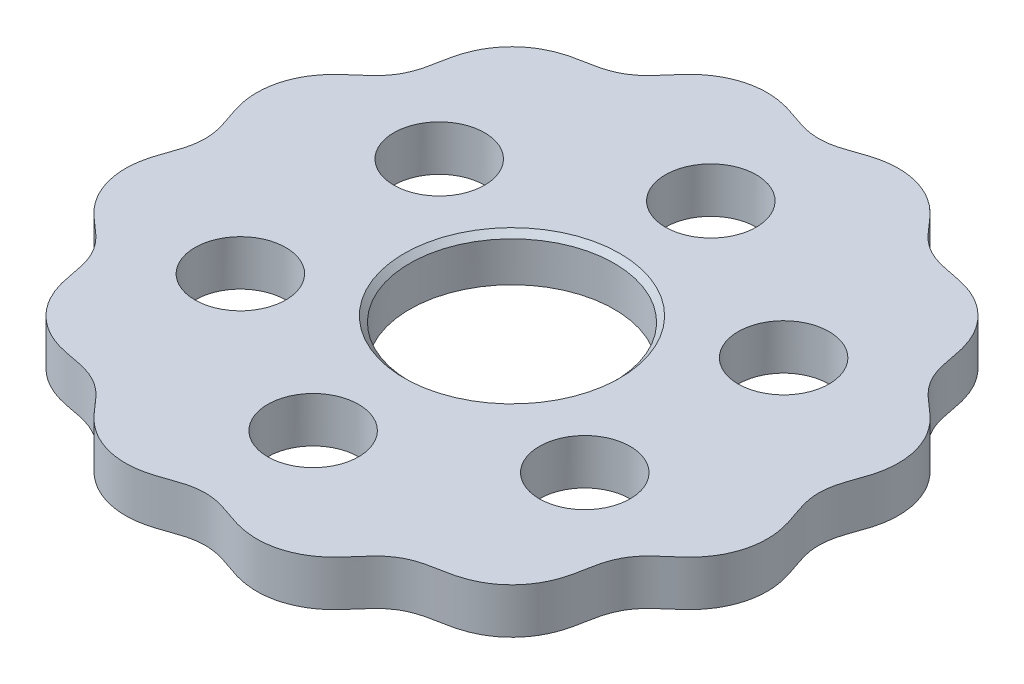
from build123d import *

# Parameters (mm, degrees)
BOSS_EXTRUDE1_DEPTH = 4
SKETCH2_R           = 9
CUT_EXTRUDE1_DEPTH  = 4
SKETCH3_R           = 4
CUT_EXTRUDE2_DEPTH  = 10
CHAMFER1_SIZE       = 0.5


with BuildPart() as part:
    # Sketch1 → Boss-Extrude1 (new body)
    with BuildSketch(Plane(origin=(0, 0, 0), x_dir=(1, 0, 0), z_dir=(0, 1, 0))):
        with BuildLine():
            add(Edge.make_bspline(
                [(27, 0), (27, -0.029843366), (27.000471765, -0.074622861), (27.002044312, -0.148526868), (27.00628274, -0.263641883), (27.012393312, -0.37537519), (27.022230728, -0.497376741), (27.03712787, -0.637409177), (27.055598892, -0.778657943), (27.077542429, -0.919236466), (27.10915909, -1.093914746), (27.153510714, -1.302382782), (27.213872001, -1.543652209), (27.292990208, -1.816594021), (27.380165946, -2.087067057), (27.473046955, -2.355596024), (27.59295323, -2.689915261), (27.737681672, -3.090771227), (27.896172741, -3.562218272), (28.063427098, -4.16720549), (28.192540962, -4.842140507), (28.27465216, -5.786972017), (28.188464813, -6.990666987), (27.810987259, -8.347530847), (27.084626542, -9.647288981), (26.186127024, -10.671759321), (25.238199473, -11.471905983), (24.372586568, -12.191039395), (23.620853175, -13.038066251), (23.063039846, -14.02515248), (22.723156568, -15.104958367), (22.540550691, -16.214937479), (22.311404563, -17.43453731), (21.855929835, -18.718964056), (21.078704809, -19.98167216), (19.944308098, -21.108107003), (18.676174537, -21.876448471), (17.388781942, -22.323268693), (16.168451287, -22.547256528), (15.058830974, -22.733329752), (13.981568641, -23.081976643), (12.999619336, -23.648776549), (12.158914933, -24.407246222), (11.442896635, -25.275122476), (10.638838498, -26.220033221), (9.608314539, -27.111685537), (8.308952362, -27.825947245), (6.766296625, -28.245380094), (5.284152953, -28.287347119), (3.944032474, -28.039779895), (2.773211959, -27.628533705), (1.720668629, -27.231619492), (0.615634296, -26.985876537), (-0.518110613, -26.975188118), (-1.627571272, -27.202504562), (-2.683196056, -27.592492668), (-3.85007581, -28.013459209), (-5.186489321, -28.279516523), (-6.675320744, -28.258945705), (-8.23569736, -27.856929805), (-9.556659448, -27.149289793), (-10.607747583, -26.253130508), (-11.424252904, -25.299053941), (-12.145498663, -24.42069207), (-12.993060357, -23.652288656), (-13.985080986, -23.079285719), (-15.074206005, -22.729094793), (-16.19549609, -22.543507448), (-17.430034502, -22.313659592), (-18.731806288, -21.851849103), (-20.00536007, -21.06206781), (-21.134053807, -19.912092302), (-21.896670407, -18.633242382), (-22.334837666, -17.34296826), (-22.553915449, -16.121964922), (-22.743815495, -15.012754256), (-23.101301577, -13.938157258), (-23.677046205, -12.961423213), (-24.442102548, -12.127035027), (-25.312028672, -11.413847459), (-26.253730695, -10.605690826), (-27.138488985, -9.569154166), (-27.843610955, -8.264810031), (-28.252168407, -6.719238227), (-28.283728903, -5.236836375), (-28.027183298, -3.898472997), (-27.611098664, -2.729600507), (-27.217360546, -1.675636661), (-26.980474187, -0.568422897), (-26.980139595, 0.565370052), (-27.216449027, 1.67272244), (-27.60997034, 2.726782849), (-28.02635931, 3.895531876), (-28.283483847, 5.233779265), (-28.252595633, 6.716195557), (-27.844741826, 8.261952815), (-27.140211848, 9.56661709), (-26.255901422, 10.60354088), (-25.314412694, 11.411968505), (-24.444361726, 12.124983159), (-23.678884788, 12.958963568), (-23.102563793, 13.935358019), (-22.744504016, 15.00977844), (-22.554344619, 16.118960967), (-22.335575088, 17.340005427), (-21.897967172, 18.63046337), (-21.135929645, 19.909659005), (-20.007760124, 21.060147962), (-18.734564151, 21.850507376), (-17.432988943, 22.312886202), (-16.19849739, 22.543076542), (-15.077182613, 22.728437444), (-13.987888625, 23.078054409), (-12.995530871, 23.650473301), (-12.147556588, 24.418443199), (-11.426126663, 25.29667015), (-10.609894266, 26.250958295), (-9.559200101, 27.147571895), (-8.238559851, 27.855810786), (-6.678365913, 28.258537364), (-5.189544443, 28.279782546), (-3.853010553, 28.014301607), (-2.686012173, 27.593622942), (-1.63049252, 27.203396622), (-0.521165891, 26.975495221), (0.612584807, 26.985514684), (1.717761904, 27.230689313), (2.77039276, 27.62740848), (3.941085326, 28.038974558), (5.281094376, 28.287123159), (6.763256705, 28.245828875), (8.306103534, 27.827098161), (9.605789274, 27.113425941), (10.636703091, 26.222217097), (11.441020578, 25.277508431), (12.156847243, 24.409493008), (12.99714314, 23.650593216), (13.978757745, 23.083213842), (15.055851496, 22.733997898), (16.165446962, 22.547688138), (17.38582278, 22.324025244), (18.673404279, 21.877764394), (19.941886401, 21.109997947), (21.076795453, 19.984079854), (21.854593687, 18.721724418), (22.310627604, 17.43749212), (22.540115396, 16.217941522), (22.722509608, 15.107940943), (23.061829575, 14.027974655), (23.619060558, 13.040559519), (24.370354006, 12.193123574), (25.235812527, 11.473780228), (26.183929614, 10.673877959), (27.082867808, 9.649802868), (27.809790294, 8.350417847), (28.187877209, 6.993819653), (28.274636512, 5.79026898), (28.193001106, 4.845542448), (28.064221926, 4.170608775), (27.897237423, 3.565701085), (27.716272452, 3.02678805), (27.521000906, 2.493508038), (27.356073412, 2.02396201), (27.232171798, 1.616745756), (27.145764302, 1.271144393), (27.08843343, 0.99468093), (27.044236171, 0.710209832), (27.019803238, 0.486134544), (27.007926019, 0.3061854), (27.002159239, 0.152753864), (27.000530427, 0.078733201), (27.000024448, 0.033939281), (27.000001572, 0.004099997)],
                knots=[0.079864449, 0.079864449, 0.079864449, 0.079864449, 0.079864449, 0.080511163, 0.080834519, 0.081157876, 0.08180459, 0.082451303, 0.083098017, 0.08374473, 0.084391444, 0.085038157, 0.086331585, 0.087625012, 0.088918439, 0.090211866, 0.091505293, 0.09279872, 0.095385574, 0.097972428, 0.100559282, 0.104219943, 0.107880604, 0.115201926, 0.122411059, 0.129620192, 0.134741434, 0.139862677, 0.144983919, 0.150105161, 0.155226231, 0.160347302, 0.165468372, 0.170589442, 0.177798511, 0.18500758, 0.192216685, 0.19942579, 0.204546942, 0.209668094, 0.214789247, 0.219910399, 0.225031553, 0.230152708, 0.235273862, 0.240395016, 0.247604122, 0.254813227, 0.262022295, 0.269231363, 0.274352432, 0.279473501, 0.284594569, 0.289715638, 0.294836882, 0.299958126, 0.30507937, 0.310200614, 0.317409748, 0.324618882, 0.331940203, 0.339261523, 0.344435233, 0.349608942, 0.354782652, 0.359956361, 0.365130069, 0.370303776, 0.375477483, 0.38065119, 0.387972512, 0.395293835, 0.402502968, 0.409712101, 0.414833341, 0.419954581, 0.425075821, 0.430197061, 0.435318133, 0.440439206, 0.445560278, 0.45068135, 0.457890419, 0.465099489, 0.472308593, 0.479517697, 0.484638848, 0.489759998, 0.494881149, 0.500002299, 0.505123455, 0.510244612, 0.515365768, 0.520486924, 0.52769603, 0.534905136, 0.542114203, 0.54932327, 0.554444337, 0.559565405, 0.564686472, 0.569807539, 0.574928785, 0.580050031, 0.585171277, 0.590292522, 0.597501657, 0.604710791, 0.612032111, 0.619353431, 0.624527142, 0.629700852, 0.634874563, 0.640048273, 0.64522198, 0.650395686, 0.655569392, 0.660743098, 0.668064421, 0.675385744, 0.682594876, 0.689804009, 0.694925247, 0.700046485, 0.705167724, 0.710288962, 0.715410036, 0.72053111, 0.725652183, 0.730773257, 0.737982327, 0.745191398, 0.752400501, 0.759609605, 0.764730753, 0.769851902, 0.774973051, 0.780094199, 0.785215357, 0.790336515, 0.795457673, 0.800578831, 0.807787938, 0.814997045, 0.822206111, 0.829415177, 0.834536243, 0.839657309, 0.844778374, 0.84989944, 0.855020687, 0.860141935, 0.865263183, 0.870384431, 0.877593566, 0.8848027, 0.892123013, 0.895783169, 0.899443325, 0.902029826, 0.904616328, 0.907202829, 0.90978933, 0.912375831, 0.913669081, 0.914962332, 0.916255583, 0.917548833, 0.918842084, 0.919165396, 0.919488709, 0.920135334, 0.920135334, 0.920135334, 0.920135334, 0.920135334], degree=4))
            Line((27.000001572, 0.004099997), (27, 0))
        make_face()
    extrude(amount=BOSS_EXTRUDE1_DEPTH)

    # Sketch2 → Cut-Extrude1 (cut)
    with BuildSketch(Plane(origin=(0, 4, 0), x_dir=(1, 0, 0), z_dir=(0, 1, 0))):
        with Locations(Location((0, 0, 0), (0, 0, 270))):
            Circle(SKETCH2_R)
    extrude(amount=-CUT_EXTRUDE1_DEPTH, mode=Mode.SUBTRACT)

    # Sketch3 → Cut-Extrude2 (cut)
    with BuildSketch(Plane(origin=(0, 4, 0), x_dir=(1, 0, 0), z_dir=(0, 1, 0))):
        with Locations(Location((0, 17.5, 0), (0, 0, 270))):
            Circle(SKETCH3_R)
        with Locations(Location((15.155444566, 8.75, 0), (0, 0, 270))):
            Circle(SKETCH3_R)
        with Locations(Location((15.155444566, -8.75, 0), (0, 0, 270))):
            Circle(SKETCH3_R)
        with Locations(Location((0, -17.5, 0), (0, 0, 270))):
            Circle(SKETCH3_R)
        with Locations(Location((-15.155444566, -8.75, 0), (0, 0, 270))):
            Circle(SKETCH3_R)
        with Locations(Location((-15.155444566, 8.75, 0), (0, 0, 270))):
            Circle(SKETCH3_R)
    extrude(amount=-CUT_EXTRUDE2_DEPTH, mode=Mode.SUBTRACT)

    # Chamfer1
    chamfer1_edges = [part.edges().sort_by_distance(p)[0] for p in [
        (0, 4, -9),
    ]]
    chamfer(chamfer1_edges, length=CHAMFER1_SIZE)


solid = part.part
